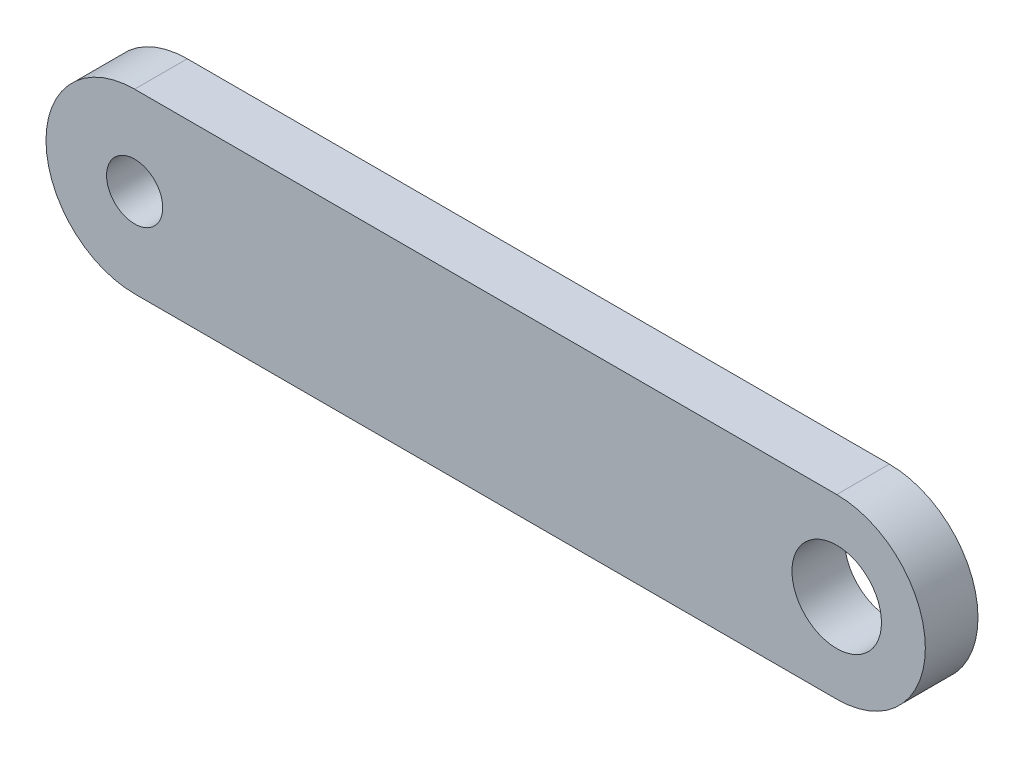
from build123d import *

# Parameters (mm, degrees)
SKETCH_1_R      = 1.6
SKETCH_1_R_2    = 2.55
EXTRUDE_1_DEPTH = 3


with BuildPart() as part:
    # 草图1 → 凸台-拉伸1 (new body)
    with BuildSketch(Plane.XY):
        with BuildLine():
            Line((-20, 5.05), (20, 5.05))
            ThreePointArc((20, 5.05), (25.05, 0), (20, -5.05))
            Line((20, -5.05), (-20, -5.05))
            ThreePointArc((-20, -5.05), (-25.05, 0), (-20, 5.05))
        make_face()
        with Locations((-20, 0)):
            Circle(SKETCH_1_R, mode=Mode.SUBTRACT)
        with Locations((20, 0)):
            Circle(SKETCH_1_R_2, mode=Mode.SUBTRACT)
    extrude(amount=EXTRUDE_1_DEPTH)


solid = part.part
